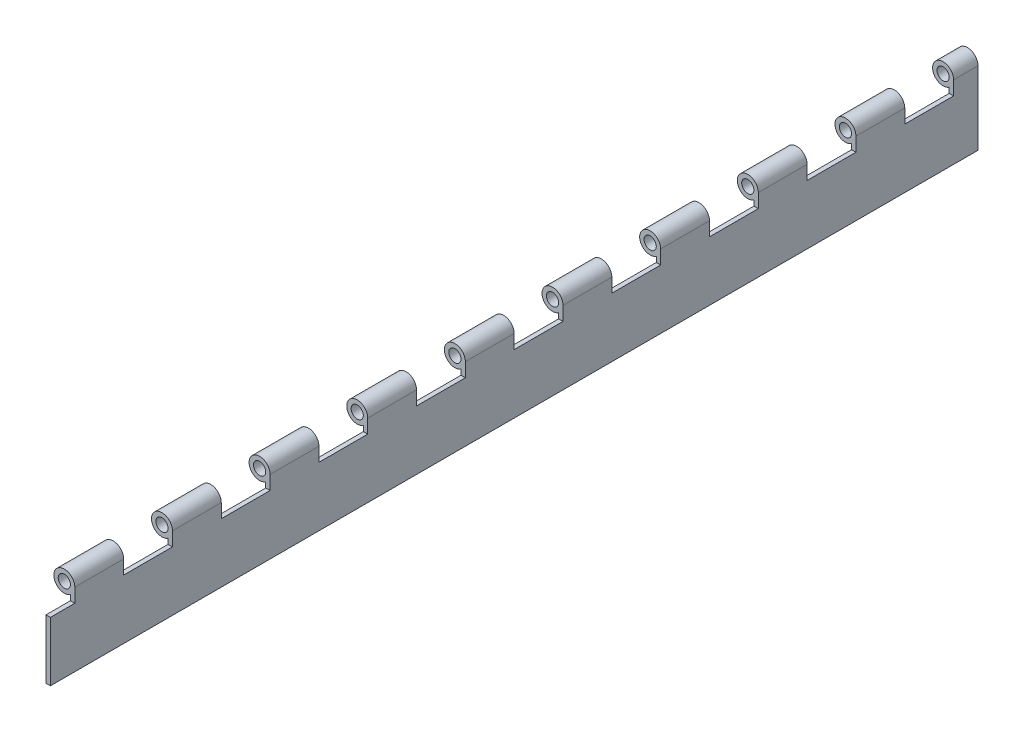
from build123d import *

# Parameters (mm, degrees)
SKETCH1_R           = 3.175
BOSS_EXTRUDE1_DEPTH = 508
SKETCH2_W           = 25.4
SKETCH2_H           = 12.7
CUT_EXTRUDE1_DEPTH  = 11.922
LPATTERN1_COUNT     = 10
LPATTERN1_PITCH     = 50.8
SKETCH4_W           = 12.7
SKETCH4_H           = 30.861
SKETCH4_H_2         = 43.561
CUT_EXTRUDE2_DEPTH  = 11.922


with BuildPart() as part:
    # Sketch1 → Boss-Extrude1 (new body)
    with BuildSketch(Plane.XY):
        with BuildLine():
            Line((5.461, 0), (5.461, -38.1))
            Line((5.461, -38.1), (3.175, -38.1))
            Line((3.175, -38.1), (3.175, -4.443185344))
            ThreePointArc((3.175, -4.443185344), (-4.855985791, 2.498384078), (5.461, 0))
        make_face()
        Circle(SKETCH1_R, mode=Mode.SUBTRACT)
    extrude(amount=BOSS_EXTRUDE1_DEPTH)

    # Sketch2 → Cut-Extrude1 (cut, through all)
    with BuildSketch(Plane(origin=(5.461, 0, 0), x_dir=(0, 0, -1), z_dir=(1, 0, 0))):
        with Locations((-495.3, -0.889)):
            Rectangle(SKETCH2_W, SKETCH2_H)
    cut_extrude1 = extrude(amount=-CUT_EXTRUDE1_DEPTH, mode=Mode.SUBTRACT)

    # LPattern1: Cut-Extrude1 ×10
    with Locations(*[(0, 0, -i * LPATTERN1_PITCH) for i in range(1, LPATTERN1_COUNT)]):
        add(cut_extrude1, mode=Mode.SUBTRACT)

    # Sketch4 → Cut-Extrude2 (cut, through all)
    with BuildSketch(Plane(origin=(5.461, 0, 0), x_dir=(0, 0, -1), z_dir=(1, 0, 0))):
        with Locations((-501.65, -22.6695)):
            Rectangle(SKETCH4_W, SKETCH4_H)
        with Locations((-6.35, -16.3195)):
            Rectangle(SKETCH4_W, SKETCH4_H_2)
    extrude(amount=-CUT_EXTRUDE2_DEPTH, mode=Mode.SUBTRACT)


solid = part.part
